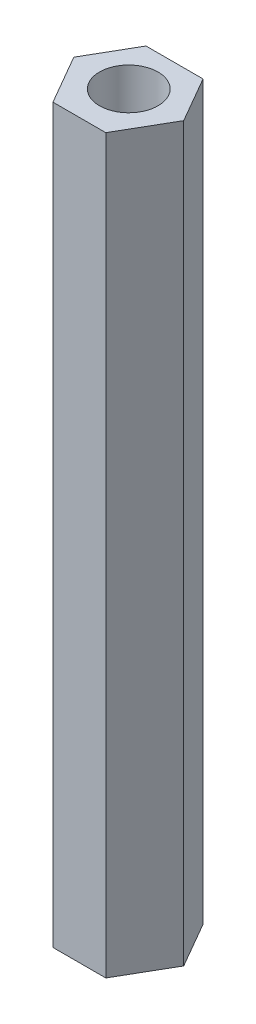
from build123d import *

# Parameters (mm, degrees)
SKETCH_1_R      = 4
EXTRUDE_1_DEPTH = 100


with BuildPart() as part:
    # 草图1 → 凸台-拉伸1 (new body)
    with BuildSketch(Plane(origin=(0, 0, 0), x_dir=(1, 0, 0), z_dir=(0, 1, 0))):
        Polygon((-3.00042007, 5.305600804), (4.790610147, 5.305600804), (8.400648538, -0.947169106), (4.50513343, -7.694399196), (-2.714943352, -7.694399196), (-6.610458461, -0.947169106), align=None)
        with Locations((0.895095039, -0.947169106)):
            Circle(SKETCH_1_R, mode=Mode.SUBTRACT)
    extrude(amount=EXTRUDE_1_DEPTH)


solid = part.part
